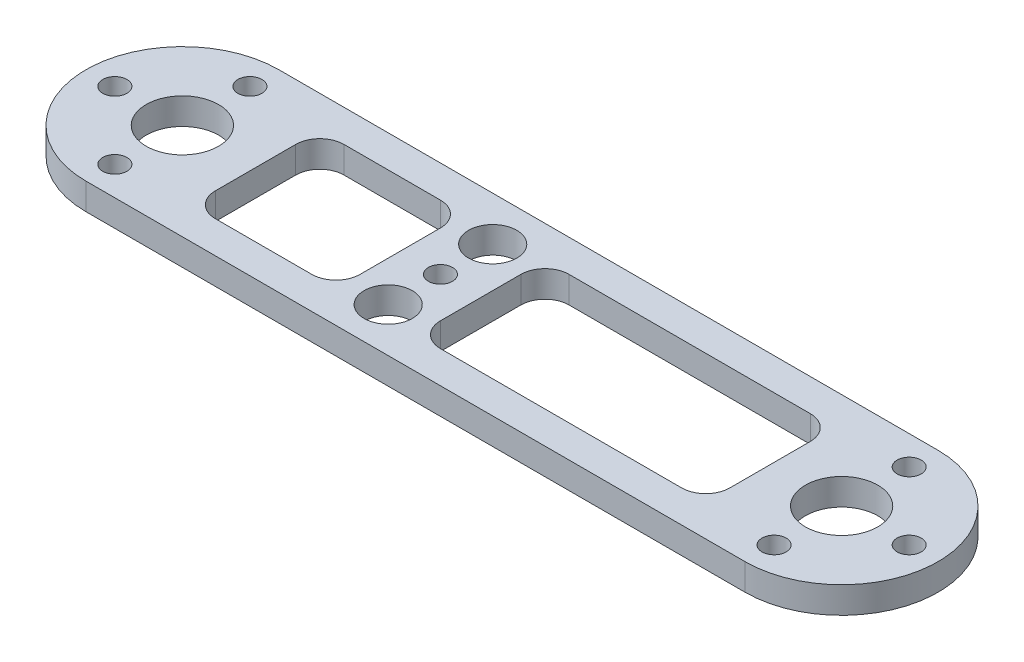
from build123d import *

# Parameters (mm, degrees)
SKETCH1_R           = 4.5
SKETCH1_R_2         = 1.5
SKETCH1_R_3         = 3
BOSS_EXTRUDE1_DEPTH = 3.3


with BuildPart() as part:
    # Sketch1 → Boss-Extrude1 (new body)
    with BuildSketch(Plane(origin=(0, 0, 0), x_dir=(1, 0, 0), z_dir=(0, 1, 0))):
        with BuildLine():
            Line((41, -12), (-41, -12))
            ThreePointArc((-41, -12), (-53, 0), (-41, 12))
            Line((-41, 12), (41, 12))
            ThreePointArc((41, 12), (53, 0), (41, -12))
        make_face()
        with Locations((41, 0)):
            Circle(SKETCH1_R, mode=Mode.SUBTRACT)
        with Locations((41, 8.4)):
            Circle(SKETCH1_R_2, mode=Mode.SUBTRACT)
        with Locations((49.4, 0)):
            Circle(SKETCH1_R_2, mode=Mode.SUBTRACT)
        with Locations((41, -8.4)):
            Circle(SKETCH1_R_2, mode=Mode.SUBTRACT)
        with Locations((-41, -8.4)):
            Circle(SKETCH1_R_2, mode=Mode.SUBTRACT)
        with Locations((-49.4, 0)):
            Circle(SKETCH1_R_2, mode=Mode.SUBTRACT)
        with Locations((-41, 8.4)):
            Circle(SKETCH1_R_2, mode=Mode.SUBTRACT)
        with Locations((-41, 0)):
            Circle(SKETCH1_R, mode=Mode.SUBTRACT)
        with Locations((-8.9, 0)):
            Circle(SKETCH1_R_2, mode=Mode.SUBTRACT)
        with Locations((-8.9, 6.5)):
            Circle(SKETCH1_R_3, mode=Mode.SUBTRACT)
        with Locations((-8.9, -6.5)):
            Circle(SKETCH1_R_3, mode=Mode.SUBTRACT)
        with BuildLine():
            Line((-0.9, 8), (29.1, 8))
            ThreePointArc((29.1, 8), (31.221320344, 7.121320344), (32.1, 5))
            Line((32.1, 5), (32.1, -5))
            ThreePointArc((32.1, -5), (31.221320344, -7.121320344), (29.1, -8))
            Line((29.1, -8), (-0.9, -8))
            ThreePointArc((-0.9, -8), (-3.021320344, -7.121320344), (-3.9, -5))
            Line((-3.9, -5), (-3.9, 5))
            ThreePointArc((-3.9, 5), (-3.021320344, 7.121320344), (-0.9, 8))
        make_face(mode=Mode.SUBTRACT)
        with BuildLine():
            Line((-28.9, 8), (-16.9, 8))
            ThreePointArc((-16.9, 8), (-14.778679656, 7.121320344), (-13.9, 5))
            Line((-13.9, 5), (-13.9, -5))
            ThreePointArc((-13.9, -5), (-14.778679656, -7.121320344), (-16.9, -8))
            Line((-16.9, -8), (-28.9, -8))
            ThreePointArc((-28.9, -8), (-31.021320344, -7.121320344), (-31.9, -5))
            Line((-31.9, -5), (-31.9, 5))
            ThreePointArc((-31.9, 5), (-31.021320344, 7.121320344), (-28.9, 8))
        make_face(mode=Mode.SUBTRACT)
    extrude(amount=BOSS_EXTRUDE1_DEPTH)


solid = part.part
